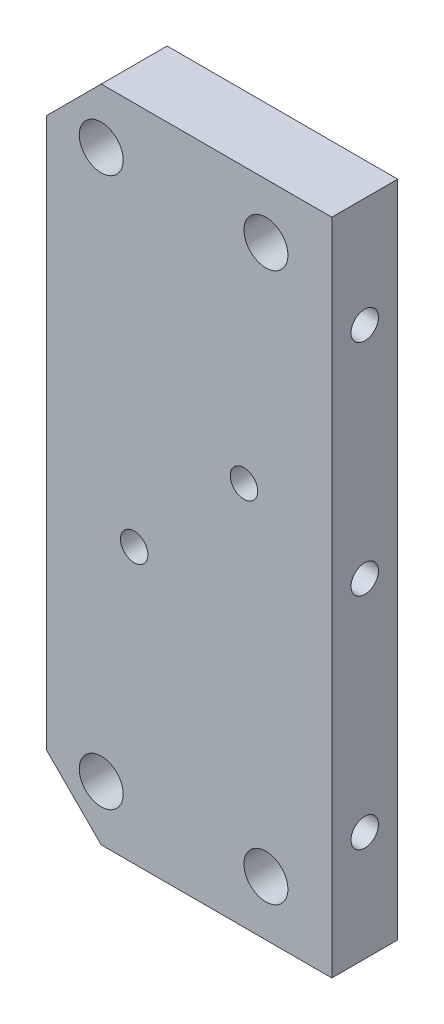
from build123d import *

# Parameters (mm, degrees)
SKETCH_1_W             = 26
SKETCH_1_H             = 60
EXTRUDE_1_DEPTH        = 6
SKETCH_2_R             = 2
CUT_EXTRUDE_1_DEPTH    = 6
HOLE_WIZARD_M3_1_D     = 2.5
HOLE_WIZARD_M3_1_DEPTH = 7.5
HOLE_WIZARD_M3_1_TIP   = 0.751075774
CHAMFER_1_SIZE         = 5
HOLE_WIZARD_M3_2_D     = 2.5
HOLE_WIZARD_M3_2_DEPTH = 7.5
HOLE_WIZARD_M3_2_TIP   = 0.751075774


with BuildPart() as part:
    # 草图1 → 凸台-拉伸1 (new body)
    with BuildSketch(Plane.XY):
        Rectangle(SKETCH_1_W, SKETCH_1_H)
    extrude(amount=EXTRUDE_1_DEPTH)

    # 草图2 → 切除-拉伸1 (cut)
    with BuildSketch(Plane(origin=(0, 0, 0), x_dir=(-1, 0, 0), z_dir=(0, 0, -1))):
        with Locations((8, -25)):
            Circle(SKETCH_2_R)
        with Locations((-7, -25)):
            Circle(SKETCH_2_R)
        with Locations((8, 25)):
            Circle(SKETCH_2_R)
        with Locations((-7, 25)):
            Circle(SKETCH_2_R)
    extrude(amount=-CUT_EXTRUDE_1_DEPTH, mode=Mode.SUBTRACT)

    # M3 螺纹孔1
    with Locations(Plane(origin=(13, 0, 0), x_dir=(0, 0, -1), z_dir=(1, 0, 0))):
        with Locations((-3, 20), (-3, 0), (-3, -20)):
            Hole(HOLE_WIZARD_M3_1_D / 2, depth=HOLE_WIZARD_M3_1_DEPTH)
            with Locations((0, 0, -(HOLE_WIZARD_M3_1_DEPTH + HOLE_WIZARD_M3_1_TIP / 2))):  # 118° drill point
                Cone(0, HOLE_WIZARD_M3_1_D / 2, HOLE_WIZARD_M3_1_TIP, mode=Mode.SUBTRACT)

    # 倒角1
    chamfer_1_edges = [part.edges().sort_by_distance(p)[0] for p in [
        (-13, 30, 3),
        (-13, -30, 3),
    ]]
    chamfer(chamfer_1_edges, length=CHAMFER_1_SIZE)

    # M3 螺纹孔2
    with Locations(Plane.XY.offset(6)):
        with Locations((5, 5), (-5, -5)):
            Hole(HOLE_WIZARD_M3_2_D / 2, depth=HOLE_WIZARD_M3_2_DEPTH)
            with Locations((0, 0, -(HOLE_WIZARD_M3_2_DEPTH + HOLE_WIZARD_M3_2_TIP / 2))):  # 118° drill point
                Cone(0, HOLE_WIZARD_M3_2_D / 2, HOLE_WIZARD_M3_2_TIP, mode=Mode.SUBTRACT)


solid = part.part
